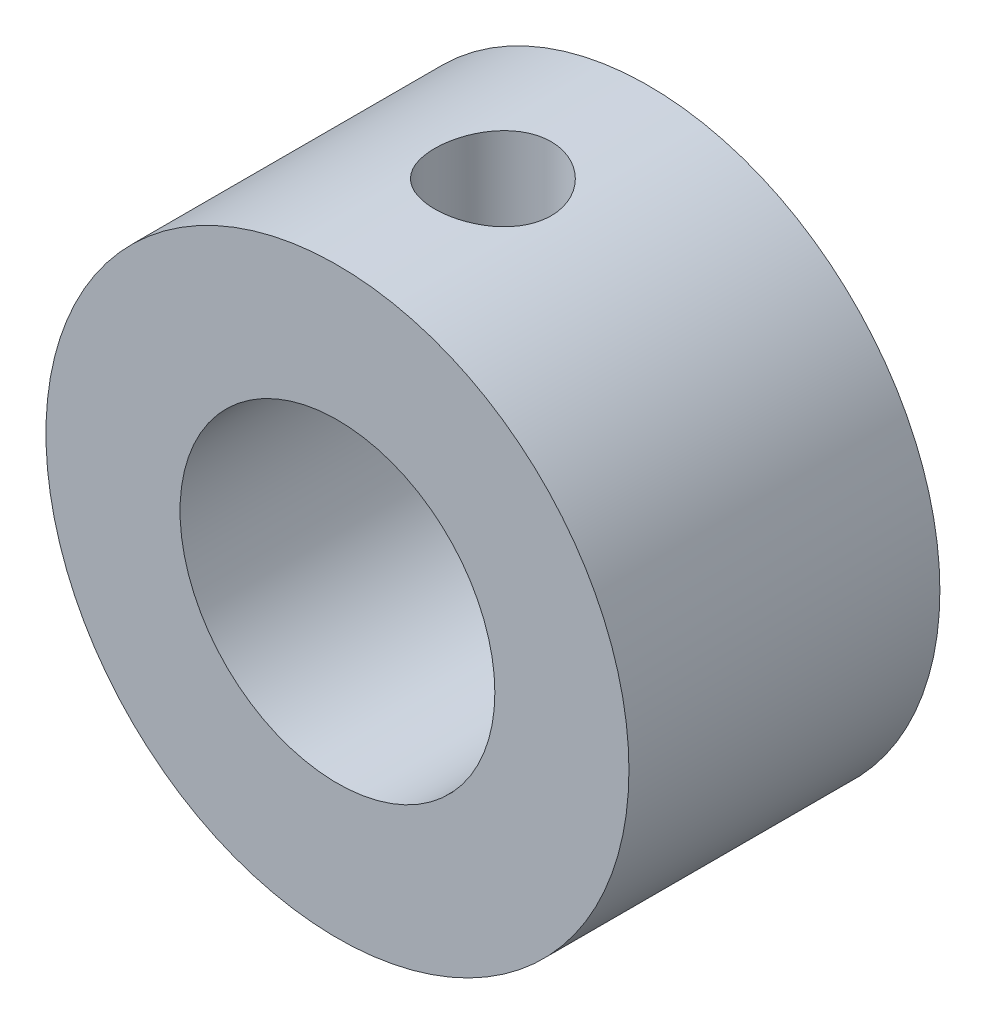
from build123d import *

# Parameters (mm, degrees)
ESQUISSE1_R             = 7.5
ESQUISSE1_R_2           = 4.05
BOSS_EXTRU_1_DEPTH      = 8
ENL_V_MAT_EXTRU_1_REACH = 17
ESQUISSE2_R             = 1.5


with BuildPart() as part:
    # Esquisse1 → Boss.-Extru.1 (new body)
    with BuildSketch(Plane.XY):
        Circle(ESQUISSE1_R)
        Circle(ESQUISSE1_R_2, mode=Mode.SUBTRACT)
    extrude(amount=BOSS_EXTRU_1_DEPTH)

    # Esquisse2 → Enlèv. mat.-Extru.1 (cut, up to next)
    with BuildSketch(Plane(origin=(0, 7.5, 0), x_dir=(1, 0, 0), z_dir=(0, 1, 0)), mode=Mode.PRIVATE) as enl_v_mat_extru_1_sk1:
        with Locations((0, -4)):
            Circle(ESQUISSE2_R)
    enl_v_mat_extru_1_tool1 = extrude(enl_v_mat_extru_1_sk1.sketch, amount=-ENL_V_MAT_EXTRU_1_REACH, mode=Mode.PRIVATE) & part.part
    add(enl_v_mat_extru_1_tool1.solids().sort_by_distance((0, 7.5, 4))[0], mode=Mode.SUBTRACT)


solid = part.part
